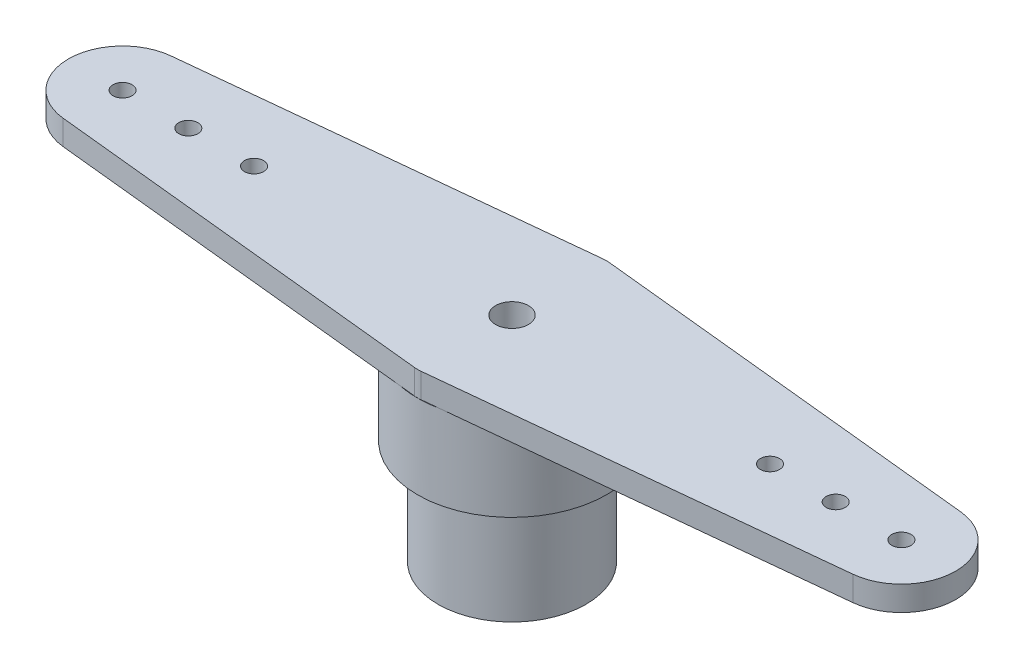
from build123d import *

# Parameters (mm, degrees)
SKETCH1_R           = 2.875
BOSS_EXTRUDE1_DEPTH = 2.55
SKETCH1_4_R         = 0.291434634
BOSS_EXTRUDE2_DEPTH = 0.75
SKETCH2_R           = 2.25
BOSS_EXTRUDE3_DEPTH = 3.2
SKETCH3_R           = 0.5
CUT_EXTRUDE1_DEPTH  = 16.256658382
FILLET1_R           = 1


with BuildPart() as part:
    # Sketch1 → Boss-Extrude1 (new body)
    with BuildSketch(Plane(origin=(0, 0, 0), x_dir=(1, 0, 0), z_dir=(0, 1, 0))):
        Circle(SKETCH1_R)
    extrude(amount=-BOSS_EXTRUDE1_DEPTH)

    # Sketch1_4 → Boss-Extrude2 (add)
    with BuildSketch(Plane(origin=(0, 0, 0), x_dir=(1, 0, 0), z_dir=(0, 1, 0))):
        with BuildLine():
            ThreePointArc((-12.018477316, 1.641376067), (-13.5, 0), (-12.018477316, -1.641376067))
            Line((-12.018477316, -1.641376067), (0, -2.875))
            Line((0, -2.875), (12.018477316, -1.641376067))
            ThreePointArc((12.018477316, -1.641376067), (13.5, 0), (12.018477316, 1.641376067))
            Line((12.018477316, 1.641376067), (0, 2.875))
            Line((0, 2.875), (-12.018477316, 1.641376067))
        make_face()
        with Locations((-11.85, 0)):
            Circle(SKETCH1_4_R, mode=Mode.SUBTRACT)
        with Locations((-9.85, 0)):
            Circle(SKETCH1_4_R, mode=Mode.SUBTRACT)
        with Locations((-7.85, 0)):
            Circle(SKETCH1_4_R, mode=Mode.SUBTRACT)
        with Locations((9.85, 0)):
            Circle(SKETCH1_4_R, mode=Mode.SUBTRACT)
        with Locations((11.85, 0)):
            Circle(SKETCH1_4_R, mode=Mode.SUBTRACT)
        with Locations((7.85, 0)):
            Circle(SKETCH1_4_R, mode=Mode.SUBTRACT)
    extrude(amount=BOSS_EXTRUDE2_DEPTH)

    # Sketch2 → Boss-Extrude3 (add)
    with BuildSketch(Plane.XZ.offset(2.55)):
        Circle(SKETCH2_R)
    extrude(amount=BOSS_EXTRUDE3_DEPTH)

    # Sketch3 → Cut-Extrude1 (cut, through all)
    with BuildSketch(Plane.XZ.offset(5.75)):
        Circle(SKETCH3_R)
    extrude(amount=-CUT_EXTRUDE1_DEPTH, mode=Mode.SUBTRACT)

    # Fillet1
    fillet1_edges = [part.edges().sort_by_distance(p)[0] for p in [
        (0, 0.375, 2.875),
        (0, 0.375, -2.875),
    ]]
    fillet(fillet1_edges, radius=FILLET1_R)


solid = part.part
